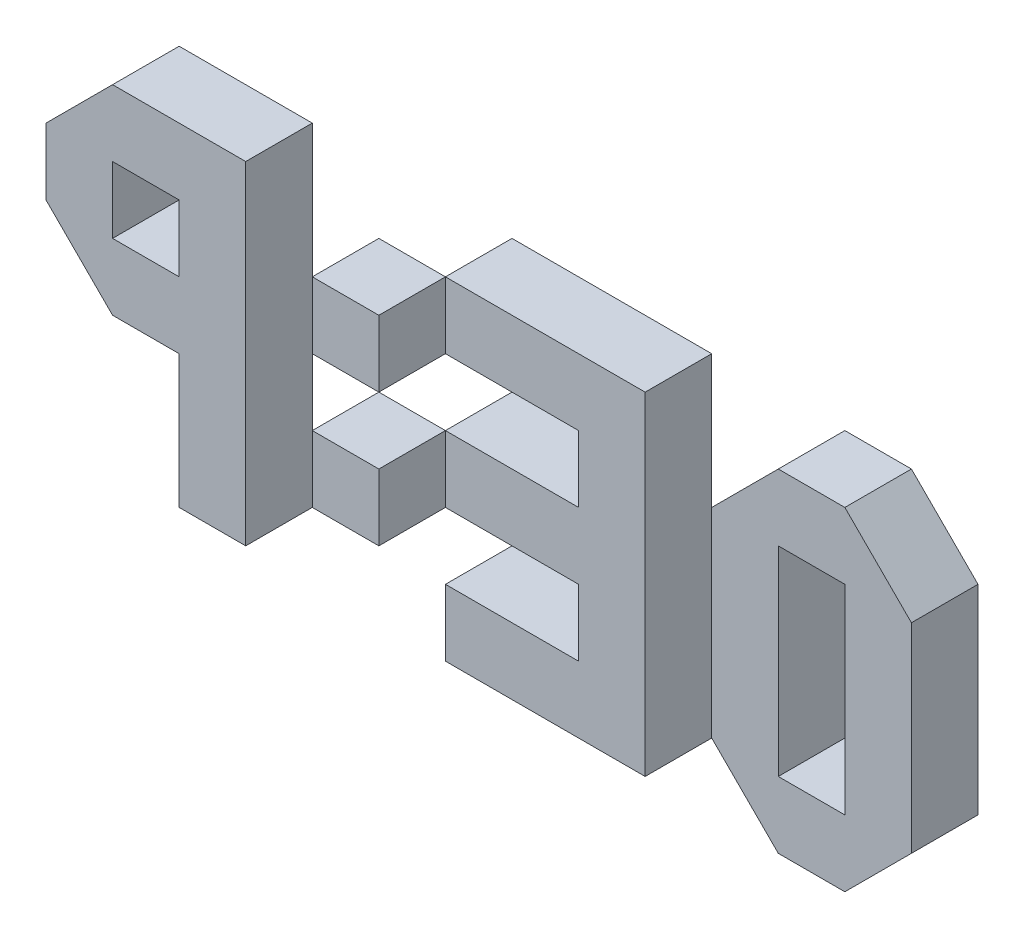
from build123d import *

# Parameters (mm, degrees)
SKETCH1_W        = 15
SKETCH1_H        = 15
EXTRUDE1_DEPTH   = 15
EXTRUDE1_2_DEPTH = 15
SKETCH1_H_2      = 45
EXTRUDE1_3_DEPTH = 15
EXTRUDE1_4_DEPTH = 15
EXTRUDE1_5_DEPTH = 15


with BuildPart() as part:
    # Sketch1 → Extrude1 (new body)
    with BuildSketch(Plane.XY):
        Polygon((30, 0), (45, 0), (45, 75), (15, 75), (0, 60), (0, 45), (15, 30), (30, 30), align=None)
        with Locations((22.5, 52.5)):
            Rectangle(SKETCH1_W, SKETCH1_H, mode=Mode.SUBTRACT)
    extrude(amount=EXTRUDE1_DEPTH)


with BuildPart() as body_2:
    # Sketch1 → Extrude1 2 (new body)
    with BuildSketch(Plane.XY):
        Polygon((90, 0), (135, 0), (135, 75), (90, 75), (90, 60), (120, 60), (120, 45), (90, 45), (90, 30), (120, 30), (120, 15), (90, 15), align=None)
    extrude(amount=EXTRUDE1_2_DEPTH)


with BuildPart() as body_3:
    # Sketch1 → Extrude1 3 (new body)
    with BuildSketch(Plane.XY):
        Polygon((195, 15), (195, 60), (180, 75), (165, 75), (150, 60), (150, 15), (165, 0), (180, 0), align=None)
        with Locations((172.5, 37.5)):
            Rectangle(SKETCH1_W, SKETCH1_H_2, mode=Mode.SUBTRACT)
    extrude(amount=EXTRUDE1_3_DEPTH)


with BuildPart() as body_4:
    # Sketch1 → Extrude1 4 (new body)
    with BuildSketch(Plane.XY):
        with Locations((67.5, 22.5)):
            Rectangle(SKETCH1_W, SKETCH1_H)
    extrude(amount=EXTRUDE1_4_DEPTH)


with BuildPart() as body_5:
    # Sketch1 → Extrude1 5 (new body)
    with BuildSketch(Plane.XY):
        with Locations((67.5, 52.5)):
            Rectangle(SKETCH1_W, SKETCH1_H)
    extrude(amount=EXTRUDE1_5_DEPTH)


solid = Compound([part.part, body_2.part, body_3.part, body_4.part, body_5.part])
